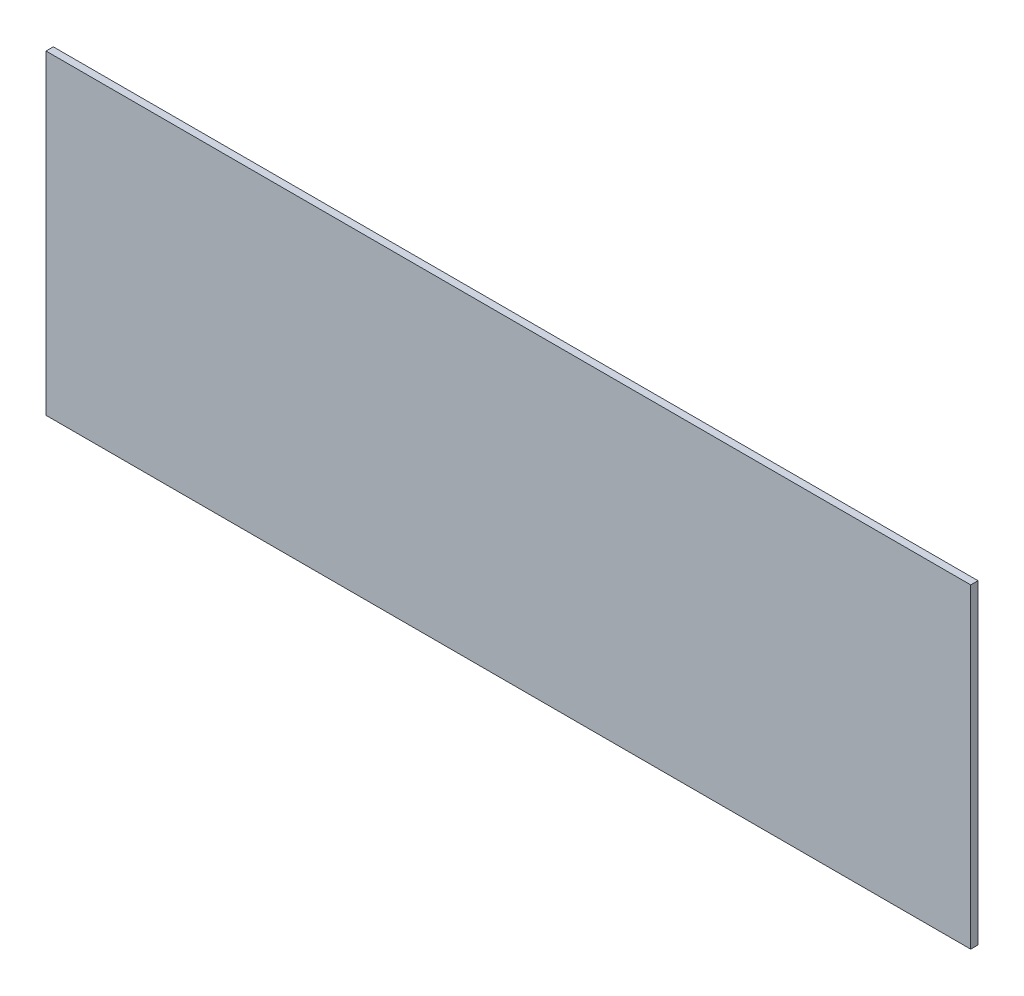
from build123d import *

# Parameters (mm, degrees)
SKETCH1_W           = 190.5
SKETCH1_H           = 65
BOSS_EXTRUDE1_DEPTH = 1.5


with BuildPart() as part:
    # Sketch1 → Boss-Extrude1 (new body)
    with BuildSketch(Plane.XY):
        Rectangle(SKETCH1_W, SKETCH1_H)
    extrude(amount=BOSS_EXTRUDE1_DEPTH)


solid = part.part
